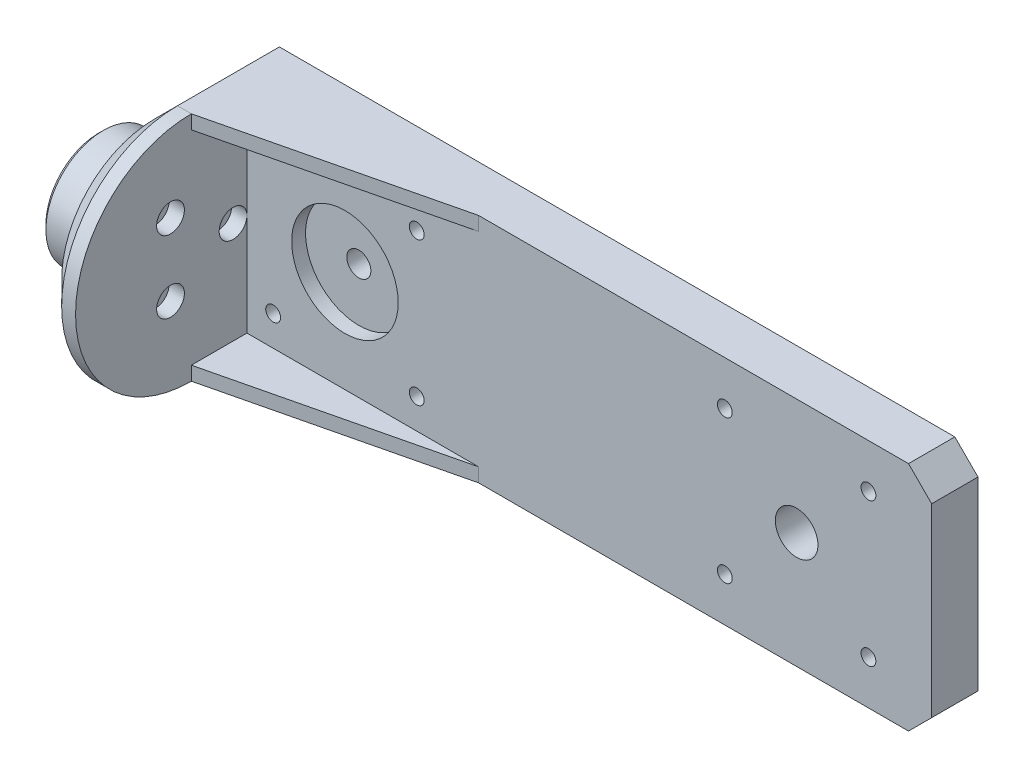
from build123d import *

# Parameters (mm, degrees)
SKETCH_2_R          = 12.4
SKETCH_2_R_2        = 1.6
EXTRUDE_1_DEPTH     = 20
EXTRUDE_2_DEPTH     = 8
SKETCH_5_W          = 155.81
SKETCH_5_H          = 50
EXTRUDE_3_DEPTH     = 10
SKETCH_6_R          = 1.6
SKETCH_6_R_2        = 2.6
SKETCH_6_R_3        = 4.6
CUT_EXTRUDE_1_DEPTH = 10
SKETCH_7_R          = 3
CUT_EXTRUDE_2_DEPTH = 3.3
SKETCH_8_R          = 11.5
CUT_EXTRUDE_3_DEPTH = 3
EXTRUDE_4_DEPTH     = 3
EXTRUDE_5_DEPTH     = 3
CHAMFER_1_SIZE      = 5
CHAMFER_2_SIZE      = 1


with BuildPart() as part:
    # 草图2 → 凸台-拉伸1 (new body)
    with BuildSketch(Plane(origin=(0, 0, 0), x_dir=(0, 0, -1), z_dir=(1, 0, 0))):
        Circle(SKETCH_2_R)
        with Locations((9, 0)):
            Circle(SKETCH_2_R_2, mode=Mode.SUBTRACT)
        with Locations((-4.5, -7.794228634)):
            Circle(SKETCH_2_R_2, mode=Mode.SUBTRACT)
        with Locations((-4.5, 7.794228634)):
            Circle(SKETCH_2_R_2, mode=Mode.SUBTRACT)
    extrude(amount=EXTRUDE_1_DEPTH)

    # 草图3 → 凸台-拉伸2 (add)
    with BuildSketch(Plane(origin=(20, 0, 0), x_dir=(0, 0, -1), z_dir=(1, 0, 0))):
        with BuildLine():
            Line((12, 25), (0, 25))
            ThreePointArc((0, 25), (-25, 0), (0, -25))
            Line((0, -25), (12, -25))
            Line((12, -25), (12, -3.12409987))
            ThreePointArc((12, -3.12409987), (-12.4, 0), (12, 3.12409987))
            Line((12, 3.12409987), (12, 25))
        make_face()
    extrude(amount=-EXTRUDE_2_DEPTH)

    # 草图5 → 凸台-拉伸3 (add)
    with BuildSketch(Plane(origin=(0, 0, -12), x_dir=(-1, 0, 0), z_dir=(0, 0, -1))):
        with Locations((-89.905, 0)):
            Rectangle(SKETCH_5_W, SKETCH_5_H)
    extrude(amount=EXTRUDE_3_DEPTH)

    # 草图6 → 切除-拉伸1 (cut)
    with BuildSketch(Plane.XY.offset(-12)):
        with Locations((25.65, 15.5)):
            Circle(SKETCH_6_R)
        with Locations((56.65, 15.5)):
            Circle(SKETCH_6_R)
        with Locations((56.65, -15.5)):
            Circle(SKETCH_6_R)
        with Locations((25.65, -15.5)):
            Circle(SKETCH_6_R)
        with Locations((41.15, 0)):
            Circle(SKETCH_6_R_2)
        with Locations((138.66, 0)):
            Circle(SKETCH_6_R_3)
        with Locations((123.16, 15.5)):
            Circle(SKETCH_6_R)
        with Locations((154.16, 15.5)):
            Circle(SKETCH_6_R)
        with Locations((154.16, -15.5)):
            Circle(SKETCH_6_R)
        with Locations((123.16, -15.5)):
            Circle(SKETCH_6_R)
    extrude(amount=-CUT_EXTRUDE_1_DEPTH, mode=Mode.SUBTRACT)

    # 草图7 → 切除-拉伸2 (cut)
    with BuildSketch(Plane(origin=(20, 0, 0), x_dir=(0, 0, -1), z_dir=(1, 0, 0))):
        with Locations((-4.5, 7.794228634)):
            Circle(SKETCH_7_R)
        with Locations((9, 0)):
            Circle(SKETCH_7_R)
        with Locations((-4.5, -7.794228634)):
            Circle(SKETCH_7_R)
    extrude(amount=-CUT_EXTRUDE_2_DEPTH, mode=Mode.SUBTRACT)

    # 草图8 → 切除-拉伸3 (cut)
    with BuildSketch(Plane.XY.offset(-12)):
        with Locations((41.15, 0)):
            Circle(SKETCH_8_R)
    extrude(amount=-CUT_EXTRUDE_3_DEPTH, mode=Mode.SUBTRACT)

    # 草图10 → 凸台-拉伸4 (add)
    with BuildSketch(Plane.XZ.offset(25)):
        Polygon((20, 0), (70, -12), (20, -12), align=None)
    extrude(amount=-EXTRUDE_4_DEPTH)

    # 草图11 → 凸台-拉伸5 (add)
    with BuildSketch(Plane(origin=(0, 25, 0), x_dir=(1, 0, 0), z_dir=(0, 1, 0))):
        Polygon((20, 0), (70, 12), (20, 12), align=None)
    extrude(amount=-EXTRUDE_5_DEPTH)

    # 倒角1
    chamfer_1_edges = [part.edges().sort_by_distance(p)[0] for p in [
        (12, 0, 25),
        (12, 25, -11),
        (12, -25, -11),
        (167.81, 25, -17),
        (167.81, -25, -17),
    ]]
    chamfer(chamfer_1_edges, length=CHAMFER_1_SIZE)

    # 倒角2
    chamfer_2_edges = [part.edges().sort_by_distance(p)[0] for p in [
        (0, 0, 12.4),
    ]]
    chamfer(chamfer_2_edges, length=CHAMFER_2_SIZE)


solid = part.part
